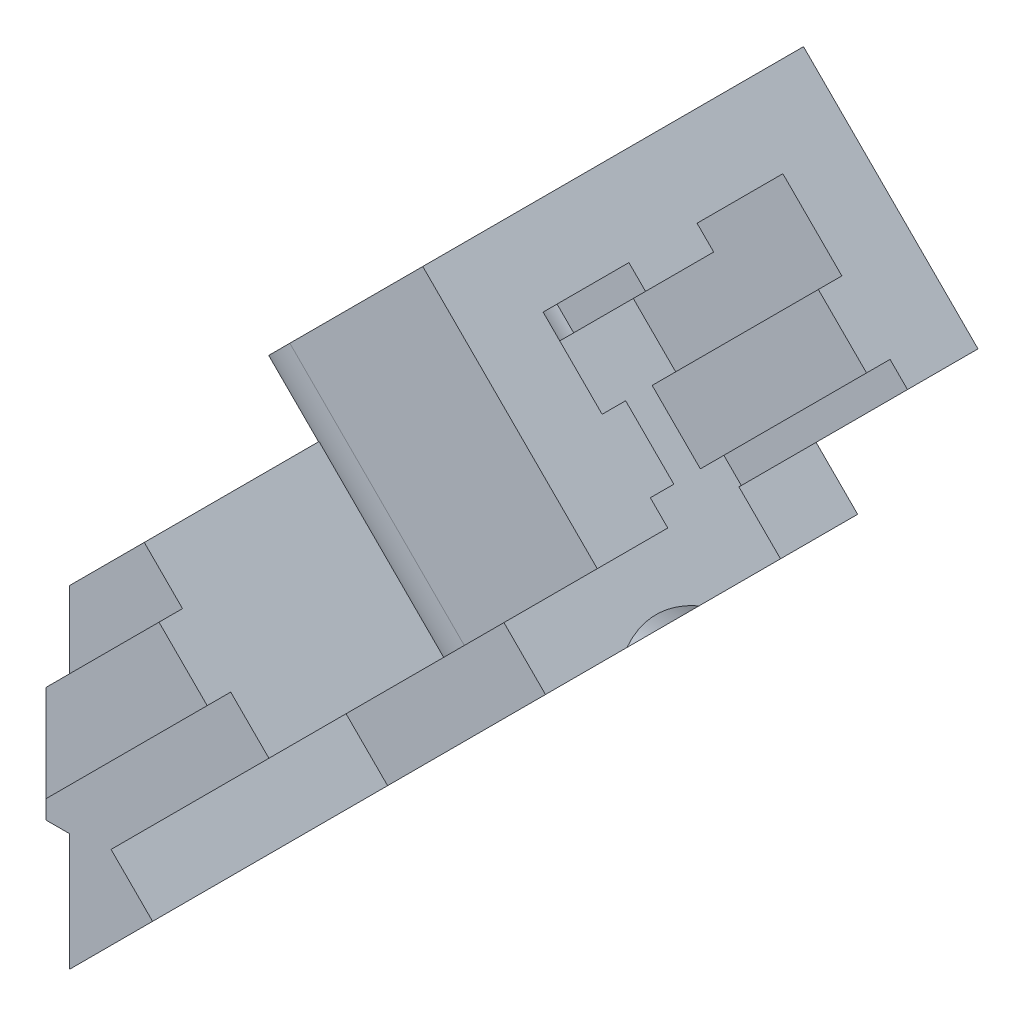
from build123d import *

# Parameters (mm, degrees)
MAIN_EXTRUSION_DEPTH                   = 15
ESQUISSE2_W                            = 10
ESQUISSE2_H                            = 9.5
WINDOW_EXTRUSION_DEPTH                 = 2.5
ESQUISSE5_R                            = 1.25
WINDOW_HOLE_EXTRUSION_DEPTH            = 11.457106781
FIXATION_TOP_MAKERBEAM_EXTRUSION_DEPTH = 10
ESQUISSE3_R                            = 1.5
WINDOW_HOLE_FIXATION_DEPTH             = 17.556349186
ESQUISSE4_R                            = 4.1
CENTRAL_FIXATION_DEPTH                 = 13.556349186
BOSS_EXTRU_2_DEPTH                     = 1
BOSS_EXTRU_6_DEPTH                     = 12
CONG_1_R                               = 4
ESQUISSE11_R                           = 1.6
ENL_V_MAT_EXTRU_2_DEPTH                = 25


with BuildPart() as part:
    # Esquisse1 → Main Extrusion (new body, symmetric)
    with BuildSketch(Plane.XY):
        Polygon((0, 0), (0, 5), (-1, 5), (-1, 7.9), (0, 7.9), (0, 14.142135624), (3.181980515, 17.324116139), (10.253048327, 10.253048327), align=None)
    extrude(amount=MAIN_EXTRUSION_DEPTH, both=True)

    # Esquisse2 → Window Extrusion (cut)
    with BuildSketch(Plane(origin=(0, 0, 0), x_dir=(0, 0, -1), z_dir=(0.707106781, -0.707106781, 0))):
        with Locations((10, 9.75)):
            Rectangle(ESQUISSE2_W, ESQUISSE2_H)
    window_extrusion = extrude(amount=-WINDOW_EXTRUSION_DEPTH, mode=Mode.SUBTRACT)

    # Esquisse5 → Window Hole Extrusion (cut, through all)
    with BuildSketch(Plane(origin=(-1.767766953, 1.767766953, 0), x_dir=(0, 0, -1), z_dir=(0.707106781, -0.707106781, 0))):
        with Locations((10, 11.5)):
            Circle(ESQUISSE5_R)
    window_hole_extrusion = extrude(amount=-WINDOW_HOLE_EXTRUSION_DEPTH, mode=Mode.SUBTRACT)

    # Esquisse7 → Fixation Top MakerBeam Extrusion (add)
    with BuildSketch(Plane(origin=(10.253048327, 10.253048327, 0), x_dir=(0, 0, -1), z_dir=(0.707106781, 0.707106781, 0))):
        Polygon((-5.1, 2.5), (-5.1, 3.55), (-4.1, 3.55), (-4.1, 6.45), (-5.1, 6.45), (-5.1, 10), (-8.1, 10), (-8.1, 2.5), align=None)
    fixation_top_makerbeam_extrusion = extrude(amount=FIXATION_TOP_MAKERBEAM_EXTRUSION_DEPTH)

    # Window Symetry: Window Extrusion, Window Hole Extrusion, Fixation Top MakerBeam Extrusion across plane
    add(window_extrusion.mirror(Plane.XY), mode=Mode.SUBTRACT)
    add(window_hole_extrusion.mirror(Plane.XY), mode=Mode.SUBTRACT)
    add(fixation_top_makerbeam_extrusion.mirror(Plane.XY))

    # Esquisse3 → Window Hole Fixation (cut, through all)
    with BuildSketch(Plane.ZY.offset(1)):
        with Locations((0, 6.45)):
            Circle(ESQUISSE3_R)
    extrude(amount=-WINDOW_HOLE_FIXATION_DEPTH, mode=Mode.SUBTRACT)

    # Esquisse4 → Central Fixation (cut, through all)
    with BuildSketch(Plane.ZY.offset(-3)):
        with Locations((0, 6.45)):
            Circle(ESQUISSE4_R)
    extrude(amount=-CENTRAL_FIXATION_DEPTH, mode=Mode.SUBTRACT)

    # Esquisse6 → Boss.-Extru.2 (add)
    with BuildSketch(Plane.XY.offset(15)):
        Polygon((0, 10.88944443), (4.808326112, 15.697770542), (6.858935778, 13.647160877), (0, 6.788225099), align=None)
    extrude(amount=BOSS_EXTRU_2_DEPTH)

    # Esquisse8 → Boss.-Extru.6 (add)
    with BuildSketch(Plane(origin=(17.324116139, 17.324116139, 0), x_dir=(0, 0, -1), z_dir=(0.707106781, 0.707106781, 0))):
        Polygon((-8.1, 10), (-1.45, 10), (-1.45, 9), (1.45, 9), (1.45, 10), (8.1, 10), (8.1, 13), (-8.1, 13), align=None)
    extrude(amount=-BOSS_EXTRU_6_DEPTH)

    # Congé1
    cong_1_edges = [part.edges().sort_by_distance(p)[0] for p in [
        (0.707106781, 16.970562748, -8.1),
        (0.707106781, 16.970562748, 8.1),
    ]]
    fillet(cong_1_edges, radius=CONG_1_R)

    # Esquisse11 → Enlèv. mat.-Extru.2 (cut, through all)
    with BuildSketch(Plane(origin=(-9.192388155, 9.192388155, 0), x_dir=(0, 0, 1), z_dir=(-0.707106781, 0.707106781, 0))):
        with Locations((0, 19.5)):
            Circle(ESQUISSE11_R)
    extrude(amount=-ENL_V_MAT_EXTRU_2_DEPTH, mode=Mode.SUBTRACT)


solid = part.part
